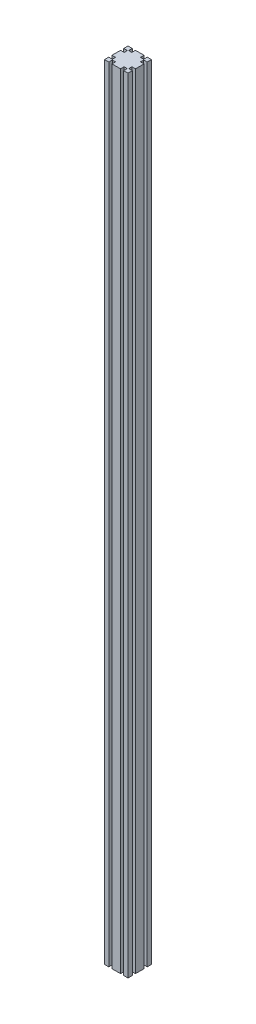
from build123d import *

# Parameters (mm, degrees)
EXTRUDE_1_DEPTH = 2000


with BuildPart() as part:
    # 草图1 → 凸台-拉伸1 (new body)
    with BuildSketch(Plane(origin=(0, 0, 0), x_dir=(1, 0, 0), z_dir=(0, 1, 0))):
        Polygon((10.9, 60), (0, 60), (0, 49.1), (9.2, 49.1), (9.2, 40.9), (0, 40.9), (0, 30), (30, 30), (30, 60), (19.1, 60), (19.1, 50.8), (10.9, 50.8), align=None)
        Polygon((30, 30), (0, 30), (0, 19.1), (9.2, 19.1), (9.2, 10.9), (0, 10.9), (0, 0), (10.9, 0), (10.9, 9.2), (19.1, 9.2), (19.1, 0), (40.9, 0), (40.9, 9.2), (49.1, 9.2), (49.1, 0), (60, 0), (60, 10.9), (50.8, 10.9), (50.8, 19.1), (60, 19.1), (60, 40.9), (50.8, 40.9), (50.8, 49.1), (60, 49.1), (60, 60), (49.1, 60), (49.1, 50.8), (40.9, 50.8), (40.9, 60), (30, 60), align=None)
    extrude(amount=EXTRUDE_1_DEPTH)


solid = part.part
